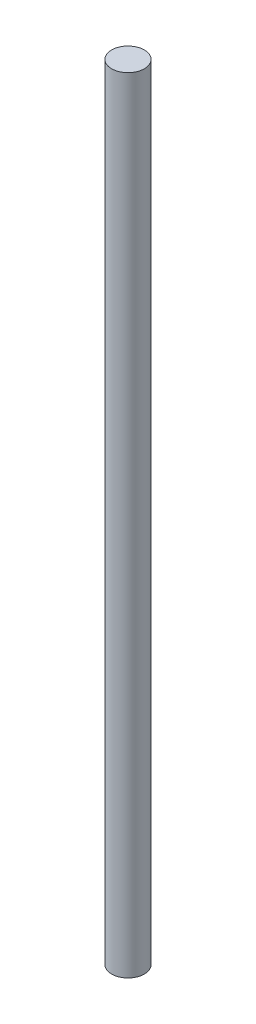
from build123d import *

# Parameters (mm, degrees)
SKETCH1_R           = 1.5875
BOSS_EXTRUDE1_DEPTH = 76.2


with BuildPart() as part:
    # Sketch1 → Boss-Extrude1 (new body)
    with BuildSketch(Plane(origin=(0, 0, 0), x_dir=(1, 0, 0), z_dir=(0, 1, 0))):
        Circle(SKETCH1_R)
    extrude(amount=BOSS_EXTRUDE1_DEPTH)


solid = part.part
